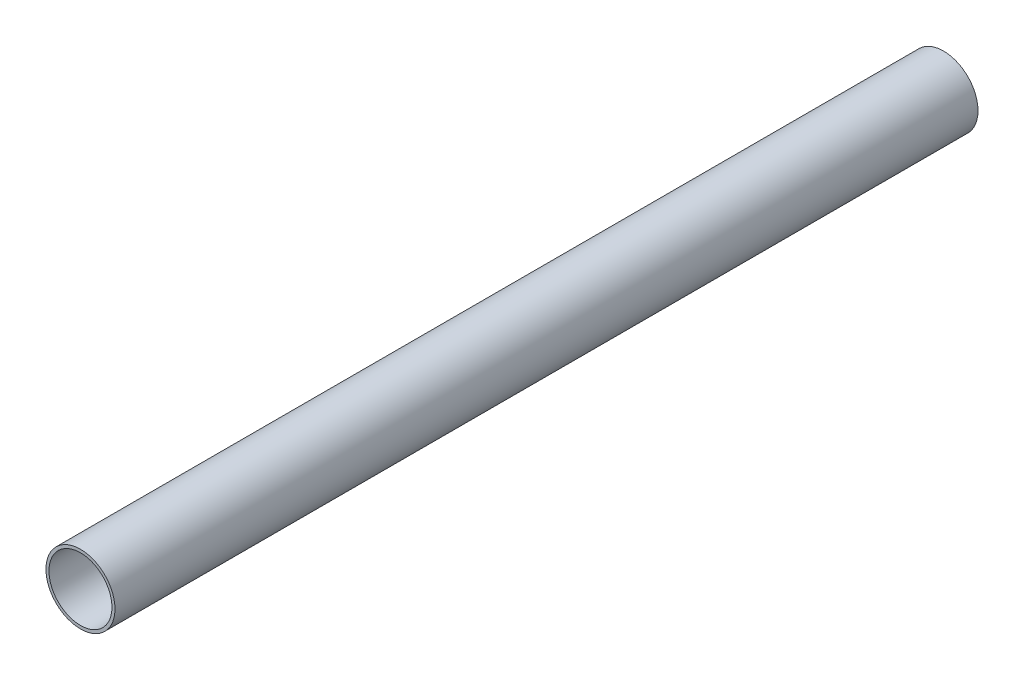
from build123d import *

# Parameters (mm, degrees)
ESQUISSE5_R        = 12
ESQUISSE5_R_2      = 10.95
BOSS_EXTRU_1_DEPTH = 300


with BuildPart() as part:
    # Esquisse5 → Boss.-Extru.1 (new body)
    with BuildSketch(Plane.XY):
        Circle(ESQUISSE5_R)
        Circle(ESQUISSE5_R_2, mode=Mode.SUBTRACT)
    extrude(amount=BOSS_EXTRU_1_DEPTH)


solid = part.part
